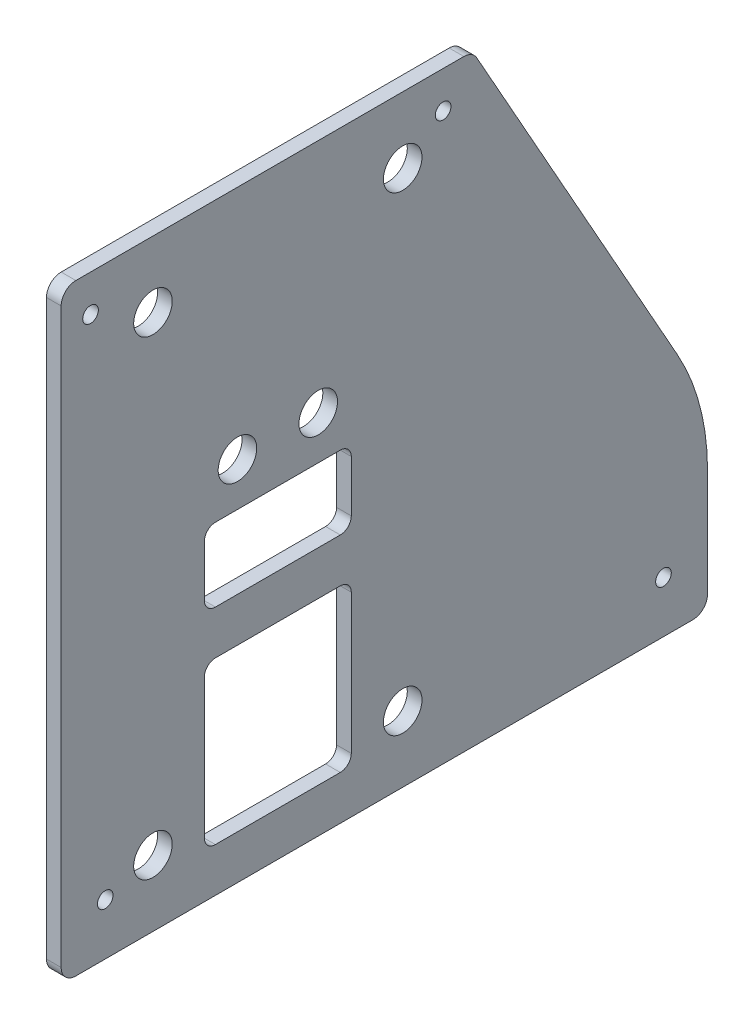
from build123d import *

# Parameters (mm, degrees)
BOSS_EXTRUDE1_DEPTH     = 6.35
F_1_4_CLEARANCE_HOLE4_D = 6.7564
F_1_4_CLEARANCE_HOLE5_D = 6.7564
FILLET4_R               = 101.6
SKETCH22_W              = 63.5
SKETCH22_H              = 69.85
SKETCH22_H_2            = 31.75
CUT_EXTRUDE1_DEPTH      = 7.35
F_5_8_CLEARANCE_HOLE1_D = 16.66748
FILLET5_R               = 6.35
FILLET6_R               = 4.7625


with BuildPart() as part:
    # Sketch1 → Boss-Extrude1 (new body)
    with BuildSketch(Plane(origin=(0, 0, 0), x_dir=(0, 0, -1), z_dir=(1, 0, 0))):
        Polygon((-279.4, 0), (-279.4, 257.175), (-101.6, 257.175), (0, 76.2), (0, 0), (0, -3.175), (-279.4, -3.175), align=None)
    extrude(amount=BOSS_EXTRUDE1_DEPTH)

    # 1/4 Clearance Hole4 (through all)
    with Locations(Plane(origin=(6.35, 0, 0), x_dir=(0, 0, -1), z_dir=(1, 0, 0))):
        with Locations((-266.7, 241.3), (-114.3, 241.3)):
            Hole(F_1_4_CLEARANCE_HOLE4_D / 2)

    # 1/4 Clearance Hole5 (through all)
    with Locations(Plane.ZY):
        with Locations((19.05, 19.05), (260.35, 19.05)):
            Hole(F_1_4_CLEARANCE_HOLE5_D / 2)

    # Fillet4
    fillet4_edges = [part.edges().sort_by_distance(p)[0] for p in [
        (3.175, 76.2, 0),
    ]]
    fillet(fillet4_edges, radius=FILLET4_R)

    # Sketch22 → Cut-Extrude1 (cut, through all)
    with BuildSketch(Plane(origin=(6.35, 0, 0), x_dir=(0, 0, -1), z_dir=(1, 0, 0))):
        with Locations((-185.7375, 50.8)):
            Rectangle(SKETCH22_W, SKETCH22_H)
        with Locations((-185.7375, 120.65)):
            Rectangle(SKETCH22_W, SKETCH22_H_2)
    extrude(amount=-CUT_EXTRUDE1_DEPTH, mode=Mode.SUBTRACT)

    # 5/8 Clearance Hole1 (through all)
    with Locations(Plane(origin=(6.35, 0, 0), x_dir=(0, 0, -1), z_dir=(1, 0, 0))):
        with Locations((-239.7125, 228.6), (-131.7625, 228.6), (-239.7125, 25.4), (-131.7625, 25.4), (-203.2, 155.324999992), (-168.275, 155.324999992)):
            Hole(F_5_8_CLEARANCE_HOLE1_D / 2)

    # Fillet5
    fillet5_edges = [part.edges().sort_by_distance(p)[0] for p in [
        (3.175, -3.175, 0),
        (3.175, -3.175, 279.4),
        (3.175, 257.175, 279.4),
        (3.175, 257.175, 101.6),
    ]]
    fillet(fillet5_edges, radius=FILLET5_R)

    # Fillet6
    fillet6_edges = [part.edges().sort_by_distance(p)[0] for p in [
        (3.175, 15.875, 217.4875),
        (3.175, 85.725, 217.4875),
        (3.175, 85.725, 153.9875),
        (3.175, 15.875, 153.9875),
        (3.175, 104.775, 217.4875),
        (3.175, 136.525, 217.4875),
        (3.175, 136.525, 153.9875),
        (3.175, 104.775, 153.9875),
    ]]
    fillet(fillet6_edges, radius=FILLET6_R)


solid = part.part
